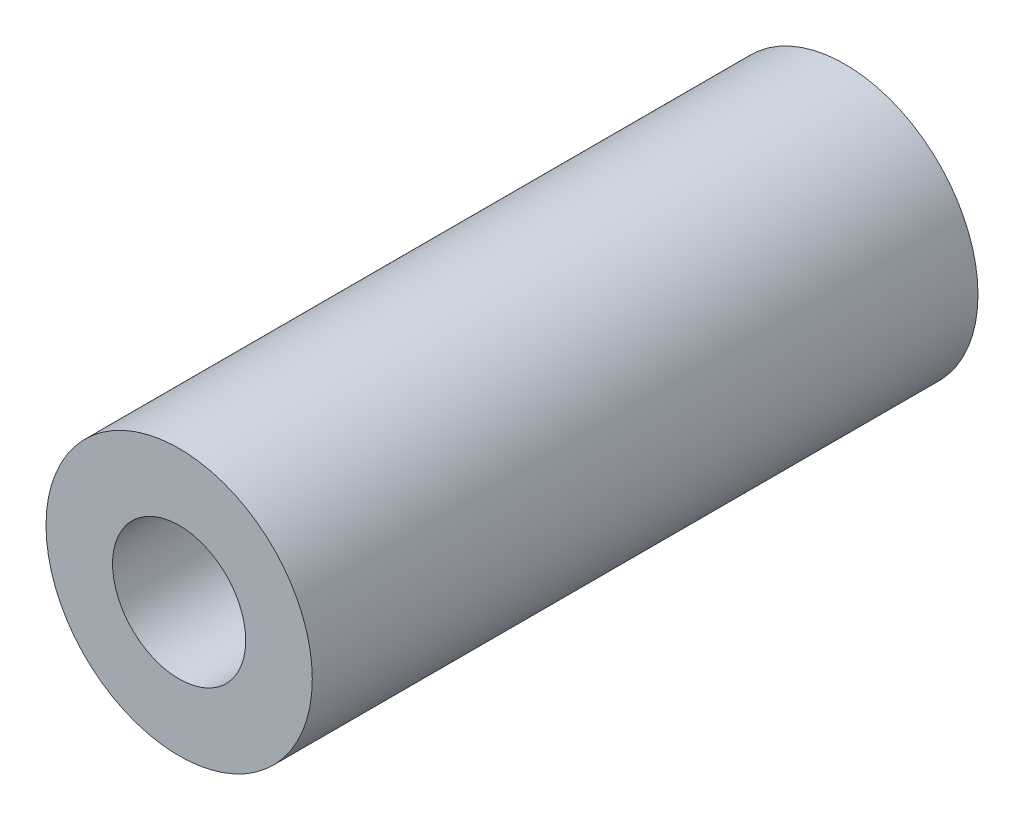
from build123d import *

# Parameters (mm, degrees)
SKETCH1_W = 5
SKETCH1_H = 50


with BuildPart() as part:
    # Sketch1 → Revolve1 (revolve)
    with BuildSketch(Plane(origin=(0, 0, 0), x_dir=(1, 0, 0), z_dir=(0, 1, 0))):
        with Locations((7.5, 0)):
            Rectangle(SKETCH1_W, SKETCH1_H)
    revolve(axis=Axis((0, 0, 25), (0, 0, -1)))


solid = part.part
